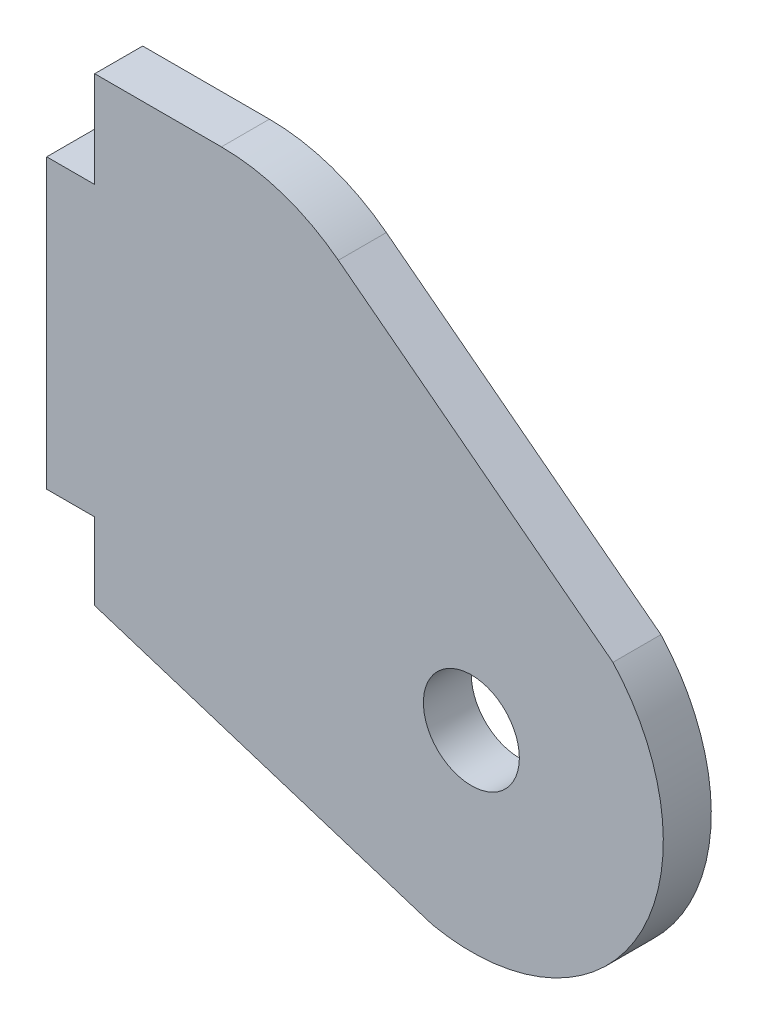
from build123d import *

# Parameters (mm, degrees)
BOSS_EXTRUDE1_DEPTH             = 3.175
F_1_4_0_25_DIAMETER_HOLE1_D     = 6.35
F_1_4_0_25_DIAMETER_HOLE1_DEPTH = 9.268267535
F_1_4_0_25_DIAMETER_HOLE1_TIP   = 1.907732465
FILLET1_R                       = 12.7


with BuildPart() as part:
    # Sketch1 → Boss-Extrude1 (new body)
    with BuildSketch(Plane.XY):
        with BuildLine():
            Line((-26.289500227, -31.481815247), (-29.464500227, -31.481815247))
            Line((-29.464500227, -31.481815247), (-29.464500227, -12.431815247))
            Line((-29.464500227, -12.431815247), (-26.289500227, -12.431815247))
            Line((-26.289500227, -12.431815247), (-26.289500227, -6.081815247))
            Line((-26.289500227, -6.081815247), (-13.589500227, -6.081815247))
            Line((-13.589500227, -6.081815247), (8.000499773, -22.666158546))
            ThreePointArc((8.000499773, -22.666158546), (9.676721644, -37.516329042), (-3.937500227, -43.67995187))
            Line((-3.937500227, -43.67995187), (-26.289500227, -36.561815247))
            Line((-26.289500227, -36.561815247), (-26.289500227, -31.481815247))
        make_face()
    extrude(amount=BOSS_EXTRUDE1_DEPTH)

    # 1/4 (0.25) Diameter Hole1
    with Locations(Plane.XY.offset(3.175)):
        with Locations((-1.365750227, -31.243067134)):
            Hole(F_1_4_0_25_DIAMETER_HOLE1_D / 2, depth=F_1_4_0_25_DIAMETER_HOLE1_DEPTH)
            with Locations((0, 0, -(F_1_4_0_25_DIAMETER_HOLE1_DEPTH + F_1_4_0_25_DIAMETER_HOLE1_TIP / 2))):  # 118° drill point
                Cone(0, F_1_4_0_25_DIAMETER_HOLE1_D / 2, F_1_4_0_25_DIAMETER_HOLE1_TIP, mode=Mode.SUBTRACT)

    # Fillet1
    fillet1_edges = [part.edges().sort_by_distance(p)[0] for p in [
        (-13.589500227, -6.081815247, 1.5875),
    ]]
    fillet(fillet1_edges, radius=FILLET1_R)


solid = part.part
